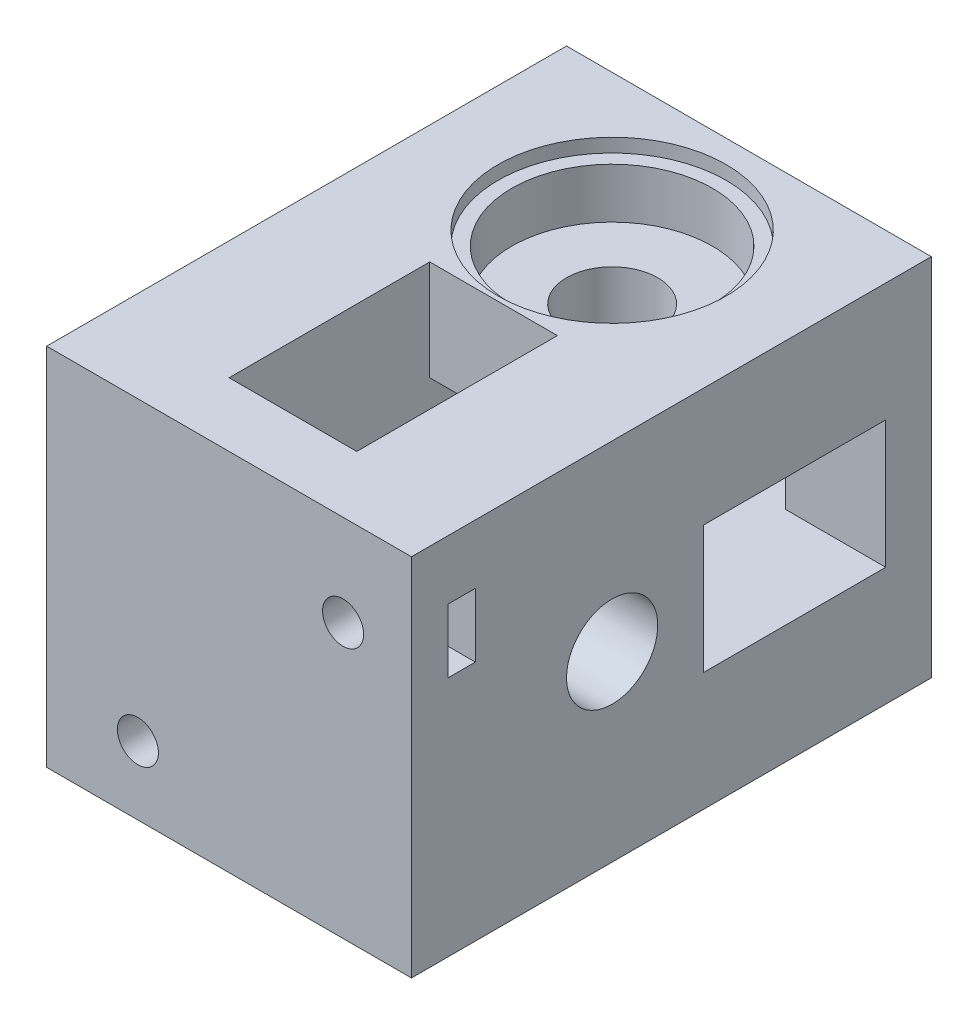
from build123d import *

# Parameters (mm, degrees)
ESQUISSE1_W              = 40
ESQUISSE1_H              = 40
BOSS_EXTRU_1_DEPTH       = 50
ESQUISSE2_R              = 5
ENL_V_MAT_EXTRU_1_DEPTH  = 41
ESQUISSE3_R              = 5
ENL_V_MAT_EXTRU_2_DEPTH  = 41
ESQUISSE4_W              = 22
ESQUISSE4_H              = 14
ENL_V_MAT_EXTRU_3_DEPTH  = 29
ESQUISSE5_W              = 14
ESQUISSE5_H              = 20
ENL_V_MAT_EXTRU_4_DEPTH  = 29
ESQUISSE6_W              = 20
ESQUISSE6_H              = 14
ENL_V_MAT_EXTRU_5_DEPTH  = 24
ESQUISSE7_W              = 14
ESQUISSE7_H              = 22
ENL_V_MAT_EXTRU_6_DEPTH  = 24
ESQUISSE10_R             = 11
ENL_V_MAT_EXTRU_9_DEPTH  = 7
ESQUISSE11_R             = 12.5
ENL_V_MAT_EXTRU_10_DEPTH = 1.5
ESQUISSE14_R             = 11
ENL_V_MAT_EXTRU_11_DEPTH = 7
ESQUISSE15_R             = 12.5
ENL_V_MAT_EXTRU_12_DEPTH = 1.5
ESQUISSE16_W             = 40
ESQUISSE16_H             = 40
BOSS_EXTRU_2_DEPTH       = 7
ESQUISSE17_R             = 2.25
ENL_V_MAT_EXTRU_13_DEPTH = 15
ESQUISSE18_W             = 7
ESQUISSE18_H             = 3
ENL_V_MAT_EXTRU_14_DEPTH = 12
ESQUISSE19_W             = 3
ESQUISSE19_H             = 7
ENL_V_MAT_EXTRU_15_DEPTH = 12


with BuildPart() as part:
    # Esquisse1 → Boss.-Extru.1 (new body)
    with BuildSketch(Plane.XY):
        with Locations((-20, 20)):
            Rectangle(ESQUISSE1_W, ESQUISSE1_H)
    extrude(amount=BOSS_EXTRU_1_DEPTH)

    # Esquisse2 → Enlèv. mat.-Extru.1 (cut, through all)
    with BuildSketch(Plane(origin=(0, 40, 0), x_dir=(1, 0, 0), z_dir=(0, 1, 0))):
        with Locations(Location((-20, -15, 0), (0, 0, 270))):  # turned: the seam where the file's is
            Circle(ESQUISSE2_R)
    extrude(amount=-ENL_V_MAT_EXTRU_1_DEPTH, mode=Mode.SUBTRACT)

    # Esquisse3 → Enlèv. mat.-Extru.2 (cut, through all)
    with BuildSketch(Plane.ZY.offset(40)):
        with Locations((35, 20)):
            Circle(ESQUISSE3_R)
    extrude(amount=-ENL_V_MAT_EXTRU_2_DEPTH, mode=Mode.SUBTRACT)

    # Esquisse4 → Enlèv. mat.-Extru.3 (cut)
    with BuildSketch(Plane.ZY.offset(40)):
        with Locations((11, 20)):
            Rectangle(ESQUISSE4_W, ESQUISSE4_H)
    extrude(amount=-ENL_V_MAT_EXTRU_3_DEPTH, mode=Mode.SUBTRACT)

    # Esquisse5 → Enlèv. mat.-Extru.4 (cut)
    with BuildSketch(Plane.XZ):
        with Locations((-20, 35)):
            Rectangle(ESQUISSE5_W, ESQUISSE5_H)
    extrude(amount=-ENL_V_MAT_EXTRU_4_DEPTH, mode=Mode.SUBTRACT)

    # Esquisse6 → Enlèv. mat.-Extru.5 (cut)
    with BuildSketch(Plane(origin=(0, 0, 0), x_dir=(0, 0, -1), z_dir=(1, 0, 0))):
        with Locations((-15, 20)):
            Rectangle(ESQUISSE6_W, ESQUISSE6_H)
    extrude(amount=-ENL_V_MAT_EXTRU_5_DEPTH, mode=Mode.SUBTRACT)

    # Esquisse7 → Enlèv. mat.-Extru.6 (cut)
    with BuildSketch(Plane(origin=(0, 40, 0), x_dir=(1, 0, 0), z_dir=(0, 1, 0))):
        with Locations((-20, -39)):
            Rectangle(ESQUISSE7_W, ESQUISSE7_H)
    extrude(amount=-ENL_V_MAT_EXTRU_6_DEPTH, mode=Mode.SUBTRACT)

    # Esquisse10 → Enlèv. mat.-Extru.9 (cut)
    with BuildSketch(Plane(origin=(0, 40, 0), x_dir=(1, 0, 0), z_dir=(0, 1, 0))):
        with Locations(Location((-20, -15, 0), (0, 0, 270))):  # turned: the seam where the file's is
            Circle(ESQUISSE10_R)
    extrude(amount=-ENL_V_MAT_EXTRU_9_DEPTH, mode=Mode.SUBTRACT)

    # Esquisse11 → Enlèv. mat.-Extru.10 (cut)
    with BuildSketch(Plane(origin=(0, 40, 0), x_dir=(1, 0, 0), z_dir=(0, 1, 0))):
        with Locations(Location((-20, -15, 0), (0, 0, 270))):  # turned: the seam where the file's is
            Circle(ESQUISSE11_R)
    extrude(amount=-ENL_V_MAT_EXTRU_10_DEPTH, mode=Mode.SUBTRACT)

    # Esquisse14 → Enlèv. mat.-Extru.11 (cut)
    with BuildSketch(Plane.ZY.offset(40)):
        with Locations((35, 20)):
            Circle(ESQUISSE14_R)
    extrude(amount=-ENL_V_MAT_EXTRU_11_DEPTH, mode=Mode.SUBTRACT)

    # Esquisse15 → Enlèv. mat.-Extru.12 (cut)
    with BuildSketch(Plane.ZY.offset(40)):
        with Locations((35, 20)):
            Circle(ESQUISSE15_R)
    extrude(amount=-ENL_V_MAT_EXTRU_12_DEPTH, mode=Mode.SUBTRACT)

    # Esquisse16 → Boss.-Extru.2 (add)
    with BuildSketch(Plane.XY.offset(50)):
        with Locations((-20, 20)):
            Rectangle(ESQUISSE16_W, ESQUISSE16_H)
    extrude(amount=BOSS_EXTRU_2_DEPTH)

    # Esquisse17 → Enlèv. mat.-Extru.13 (cut)
    with BuildSketch(Plane.XY.offset(57)):
        with Locations((-30, 7.5)):
            Circle(ESQUISSE17_R)
        with Locations((-7.5, 30)):
            Circle(ESQUISSE17_R)
    extrude(amount=-ENL_V_MAT_EXTRU_13_DEPTH, mode=Mode.SUBTRACT)

    # Esquisse18 → Enlèv. mat.-Extru.14 (cut)
    with BuildSketch(Plane.XZ):
        with Locations((-30, 51.5)):
            Rectangle(ESQUISSE18_W, ESQUISSE18_H)
    extrude(amount=-ENL_V_MAT_EXTRU_14_DEPTH, mode=Mode.SUBTRACT)

    # Esquisse19 → Enlèv. mat.-Extru.15 (cut)
    with BuildSketch(Plane(origin=(0, 0, 0), x_dir=(0, 0, -1), z_dir=(1, 0, 0))):
        with Locations((-51.5, 30)):
            Rectangle(ESQUISSE19_W, ESQUISSE19_H)
    extrude(amount=-ENL_V_MAT_EXTRU_15_DEPTH, mode=Mode.SUBTRACT)


solid = part.part
